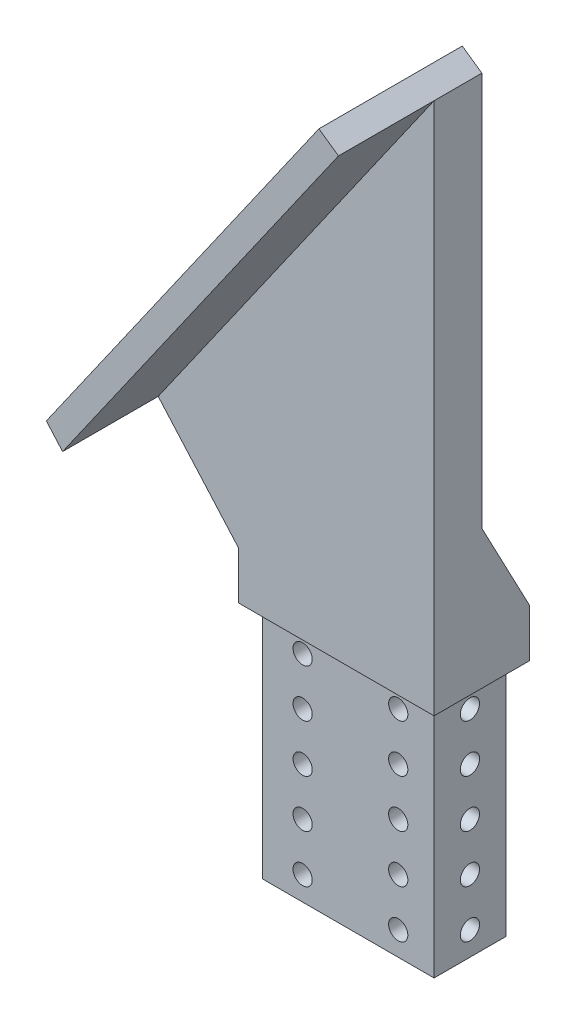
from build123d import *

# Parameters (mm, degrees)
BOSS_EXTRUDE1_DEPTH     = 25.4
SKETCH2_W               = 52
SKETCH2_H               = 63.5
CUT_EXTRUDE1_DEPTH      = 3.175
SKETCH3_W               = 25.4
SKETCH3_H               = 63.5
CUT_EXTRUDE2_DEPTH      = 3.175
SKETCH4_W               = 52
SKETCH4_H               = 63.5
CUT_EXTRUDE3_DEPTH      = 3.175
SKETCH5_W               = 25.4
SKETCH5_H               = 63.5
CUT_EXTRUDE4_DEPTH      = 3.175
SKETCH6_R               = 2.5527
CUT_EXTRUDE5_DEPTH      = 23.225
SKETCH7_R               = 2.5527
CUT_EXTRUDE6_DEPTH      = 150.825
SKETCH8_W               = 101
SKETCH8_H               = 177.8
CUT_EXTRUDE7_DEPTH      = 26.4
CUT_EXTRUDE8_DEPTH      = 1
CUT_EXTRUDE8_DEPTH_BACK = 26.4
CUT_EXTRUDE9_DEPTH      = 26.4
CUT_EXTRUDE10_DEPTH     = 26.4
BOSS_EXTRUDE2_DEPTH     = 25.4
CUT_EXTRUDE11_DEPTH     = 51.8
CUT_EXTRUDE12_DEPTH     = 51.8
CUT_EXTRUDE13_DEPTH     = 93.323036631
CUT_EXTRUDE14_DEPTH     = 51.8
CUT_EXTRUDE15_DEPTH     = 26.4
CUT_EXTRUDE16_DEPTH     = 51.8


with BuildPart() as part:
    # Sketch1 → Boss-Extrude1 (new body)
    with BuildSketch(Plane.XY):
        Polygon((0, 0), (0, 76.2), (-101, 76.2), (-101, 254), (153, 254), (153, 76.2), (52, 76.2), (52, 0), align=None)
    extrude(amount=BOSS_EXTRUDE1_DEPTH)

    # Sketch2 → Cut-Extrude1 (cut)
    with BuildSketch(Plane.XY.offset(25.4)):
        with Locations((26, 31.75)):
            Rectangle(SKETCH2_W, SKETCH2_H)
    extrude(amount=-CUT_EXTRUDE1_DEPTH, mode=Mode.SUBTRACT)

    # Sketch3 → Cut-Extrude2 (cut)
    with BuildSketch(Plane.ZY):
        with Locations((12.7, 31.75)):
            Rectangle(SKETCH3_W, SKETCH3_H)
    extrude(amount=-CUT_EXTRUDE2_DEPTH, mode=Mode.SUBTRACT)

    # Sketch4 → Cut-Extrude3 (cut)
    with BuildSketch(Plane(origin=(0, 0, 0), x_dir=(-1, 0, 0), z_dir=(0, 0, -1))):
        with Locations((-26, 31.75)):
            Rectangle(SKETCH4_W, SKETCH4_H)
    extrude(amount=-CUT_EXTRUDE3_DEPTH, mode=Mode.SUBTRACT)

    # Sketch5 → Cut-Extrude4 (cut)
    with BuildSketch(Plane(origin=(52, 0, 0), x_dir=(0, 0, -1), z_dir=(1, 0, 0))):
        with Locations((-12.7, 31.75)):
            Rectangle(SKETCH5_W, SKETCH5_H)
    extrude(amount=-CUT_EXTRUDE4_DEPTH, mode=Mode.SUBTRACT)

    # Sketch6 → Cut-Extrude5 (cut, through all)
    with BuildSketch(Plane(origin=(0, 0, 3.175), x_dir=(-1, 0, 0), z_dir=(0, 0, -1))):
        with Locations((-39.3, 57.15)):
            Circle(SKETCH6_R)
        with Locations((-13.9, 57.15)):
            Circle(SKETCH6_R)
        with Locations((-39.3, 44.45)):
            Circle(SKETCH6_R)
        with Locations((-13.9, 44.45)):
            Circle(SKETCH6_R)
        with Locations((-39.3, 31.75)):
            Circle(SKETCH6_R)
        with Locations((-13.9, 31.75)):
            Circle(SKETCH6_R)
        with Locations((-39.3, 19.05)):
            Circle(SKETCH6_R)
        with Locations((-13.9, 19.05)):
            Circle(SKETCH6_R)
        with Locations((-39.3, 6.35)):
            Circle(SKETCH6_R)
        with Locations((-13.9, 6.35)):
            Circle(SKETCH6_R)
    extrude(amount=-CUT_EXTRUDE5_DEPTH, mode=Mode.SUBTRACT)

    # Sketch7 → Cut-Extrude6 (cut, through all)
    with BuildSketch(Plane(origin=(48.825, 0, 0), x_dir=(0, 0, -1), z_dir=(1, 0, 0))):
        with Locations((-12.7, 57.15)):
            Circle(SKETCH7_R)
        with Locations((-12.7, 44.45)):
            Circle(SKETCH7_R)
        with Locations((-12.7, 31.75)):
            Circle(SKETCH7_R)
        with Locations((-12.7, 19.05)):
            Circle(SKETCH7_R)
        with Locations((-12.7, 6.35)):
            Circle(SKETCH7_R)
    extrude(amount=-CUT_EXTRUDE6_DEPTH, mode=Mode.SUBTRACT)

    # Sketch8 → Cut-Extrude7 (cut, through all)
    with BuildSketch(Plane.XY.offset(25.4)):
        with Locations((102.5, 165.1)):
            Rectangle(SKETCH8_W, SKETCH8_H)
    extrude(amount=-CUT_EXTRUDE7_DEPTH, mode=Mode.SUBTRACT)

    # Sketch9 → Cut-Extrude8 (cut, two sides)
    with BuildSketch(Plane.XY.offset(25.4)) as cut_extrude8_sk:
        Polygon((52, 254), (52, 242.697), (35.85764308, 254), align=None)
    extrude(amount=CUT_EXTRUDE8_DEPTH, mode=Mode.SUBTRACT)
    extrude(cut_extrude8_sk.sketch, amount=-CUT_EXTRUDE8_DEPTH_BACK, mode=Mode.SUBTRACT)

    # Sketch10 → Cut-Extrude9 (cut, through all)
    with BuildSketch(Plane.XY.offset(25.4)):
        Polygon((35.85764308, 254), (-101, 58.547029828), (-101, 254), align=None)
    extrude(amount=-CUT_EXTRUDE9_DEPTH, mode=Mode.SUBTRACT)

    # Sketch11 → Cut-Extrude10 (cut, through all)
    with BuildSketch(Plane.XY.offset(25.4)):
        Polygon((35.85764308, 254), (46.79768076, 246.339703148), (-82.829822213, 61.212443159), (-93.769859893, 68.872740011), align=None)
    extrude(amount=-CUT_EXTRUDE10_DEPTH, mode=Mode.SUBTRACT)

    # Sketch14 → Boss-Extrude2 (add)
    with BuildSketch(Plane.XY.offset(25.4)):
        Polygon((46.79768076, 246.339703148), (69.685492552, 230.313484798), (-62.703014112, 41.243102891), (-85.590825904, 57.26932124), align=None)
    extrude(amount=BOSS_EXTRUDE2_DEPTH)

    # Sketch15 → Cut-Extrude11 (cut, through all)
    with BuildSketch(Plane.XY.offset(50.8)):
        Polygon((-38.225931244, 76.2), (-72.335421933, 76.2), (-85.590825904, 57.26932124), (-62.703014112, 41.243102891), align=None)
    extrude(amount=-CUT_EXTRUDE11_DEPTH, mode=Mode.SUBTRACT)

    # Sketch16 → Cut-Extrude12 (cut, through all)
    with BuildSketch(Plane(origin=(0, 0, 0), x_dir=(-1, 0, 0), z_dir=(0, 0, -1))):
        Polygon((0, 76.2), (40.323036631, 121.918424261), (72.335421933, 76.2), align=None)
    extrude(amount=-CUT_EXTRUDE12_DEPTH, mode=Mode.SUBTRACT)

    # Sketch17 → Cut-Extrude13 (cut, through all)
    with BuildSketch(Plane(origin=(52, 0, 0), x_dir=(0, 0, -1), z_dir=(1, 0, 0))):
        Polygon((-12.7, 246.339703148), (-12.7, 100.289703148), (0, 76.2), (0, 246.339703148), align=None)
    extrude(amount=-CUT_EXTRUDE13_DEPTH, mode=Mode.SUBTRACT)

    # Sketch18 → Cut-Extrude14 (cut, through all)
    with BuildSketch(Plane.XY.offset(50.8)):
        Polygon((64.483173396, 233.956187887), (-27.012035852, 103.287487173), (-44.697528488, 115.671002434), (46.79768076, 246.339703148), align=None)
    extrude(amount=-CUT_EXTRUDE14_DEPTH, mode=Mode.SUBTRACT)

    # Sketch19 → Cut-Extrude15 (cut, through all)
    with BuildSketch(Plane(origin=(0, 0, 25.4), x_dir=(-1, 0, 0), z_dir=(0, 0, -1))):
        Polygon((-52, 205.055983862), (-52, 216.128368684), (-64.483173396, 233.956187887), (-69.685492552, 230.313484798), align=None)
    extrude(amount=-CUT_EXTRUDE15_DEPTH, mode=Mode.SUBTRACT)

    # Sketch20 → Cut-Extrude16 (cut, through all)
    with BuildSketch(Plane.XY.offset(50.8)):
        Polygon((52, 205.055983862), (46.797680844, 208.698686951), (52, 216.128368684), align=None)
    extrude(amount=-CUT_EXTRUDE16_DEPTH, mode=Mode.SUBTRACT)


solid = part.part
